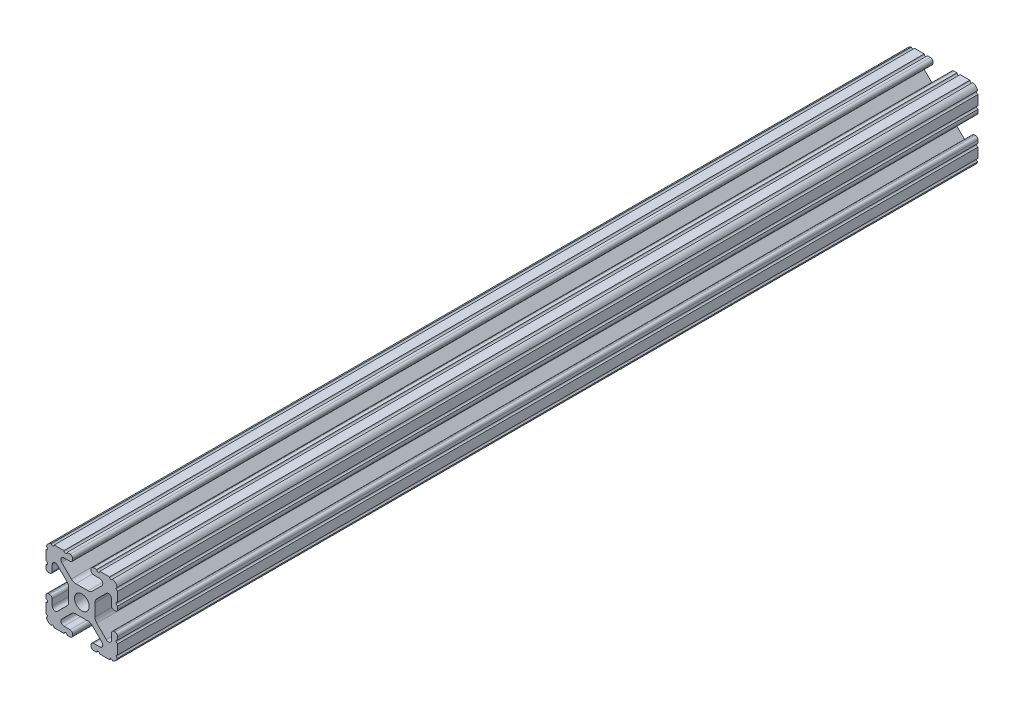
from build123d import *

# Parameters (mm, degrees)
BOSS_EXTRUDE1_DEPTH     = 304.8
SKETCH5_R               = 0.55245
CUT_EXTRUDE1_DEPTH      = 305.8
CUT_EXTRUDE1_DEPTH_BACK = 305.8
SKETCH6_W               = 73.397173187
SKETCH6_H               = 48.877854652
CUT_EXTRUDE2_DEPTH      = 304.8


with BuildPart() as part:
    # Sketch4 → Boss-Extrude1 (new body, symmetric)
    with BuildSketch(Plane.XY):
        with BuildLine():
            Line((4.190365, -12.7), (10.11729625, -12.7))
            ThreePointArc((10.11729625, -12.7), (11.943543585, -11.943543585), (12.7, -10.11729625))
            Line((12.7, -10.11729625), (12.7, -4.190365))
            ThreePointArc((12.7, -4.190365), (12.42492494, -3.52627506), (11.760835, -3.2512))
            Line((11.760835, -3.2512), (11.429365, -3.2512))
            ThreePointArc((11.429365, -3.2512), (10.76527506, -3.52627506), (10.4902, -4.190365))
            Line((10.4902, -4.190365), (10.4902, -6.348478019))
            ThreePointArc((10.4902, -6.348478019), (9.830707141, -7.335478831), (8.666460301, -7.103895736))
            Line((8.666460301, -7.103895736), (5.299899128, -3.737334563))
            ThreePointArc((5.299899128, -3.737334563), (4.817571085, -3.015479634), (4.6482, -2.16399369))
            Line((4.6482, -2.16399369), (4.6482, 0))
            Line((4.6482, 0), (2.6035, 0))
            ThreePointArc((2.6035, 0), (1.840952505, -1.840952505), (0, -2.6035))
            Line((0, -2.6035), (0, -4.6482))
            Line((0, -4.6482), (2.16399369, -4.6482))
            ThreePointArc((2.16399369, -4.6482), (3.015479634, -4.817571085), (3.737334563, -5.299899128))
            Line((3.737334563, -5.299899128), (7.103895736, -8.666460301))
            ThreePointArc((7.103895736, -8.666460301), (7.335478831, -9.830707141), (6.348478019, -10.4902))
            Line((6.348478019, -10.4902), (4.190365, -10.4902))
            ThreePointArc((4.190365, -10.4902), (3.52627506, -10.76527506), (3.2512, -11.429365))
            Line((3.2512, -11.429365), (3.2512, -11.760835))
            ThreePointArc((3.2512, -11.760835), (3.52627506, -12.42492494), (4.190365, -12.7))
        make_face()
    extrude(amount=BOSS_EXTRUDE1_DEPTH, both=True)

    # Sketch5 → Cut-Extrude1 (cut, two sides)
    with BuildSketch(Plane.XY) as cut_extrude1_sk:
        with Locations((10.356153152, -12.7)):
            Circle(SKETCH5_R)
        with Locations((5.796028019, -12.7)):
            Circle(SKETCH5_R)
        with Locations((12.7, -10.356153152)):
            Circle(SKETCH5_R)
        with Locations((12.7, -5.796028019)):
            Circle(SKETCH5_R)
    extrude(amount=CUT_EXTRUDE1_DEPTH, mode=Mode.SUBTRACT)
    extrude(cut_extrude1_sk.sketch, amount=-CUT_EXTRUDE1_DEPTH_BACK, mode=Mode.SUBTRACT)

    # Mirror1: part across plane


with BuildPart() as part_1:
    add(part.part)
    add(part.part.mirror(Plane(origin=(0, 0, 0), x_dir=(0, 0, 1), z_dir=(1, 0, 0))))

    # Mirror2: part across plane


with BuildPart() as part_2:
    add(part_1.part)
    add(part_1.part.mirror(Plane.ZX))

    # Sketch6 → Cut-Extrude2 (cut)
    with BuildSketch(Plane(origin=(0, 0, -304.8), x_dir=(-1, 0, 0), z_dir=(0, 0, -1))):
        with Locations((-1.205868125, 1.286259333)):
            Rectangle(SKETCH6_W, SKETCH6_H)
    extrude(amount=-CUT_EXTRUDE2_DEPTH, mode=Mode.SUBTRACT)


solid = part_2.part
